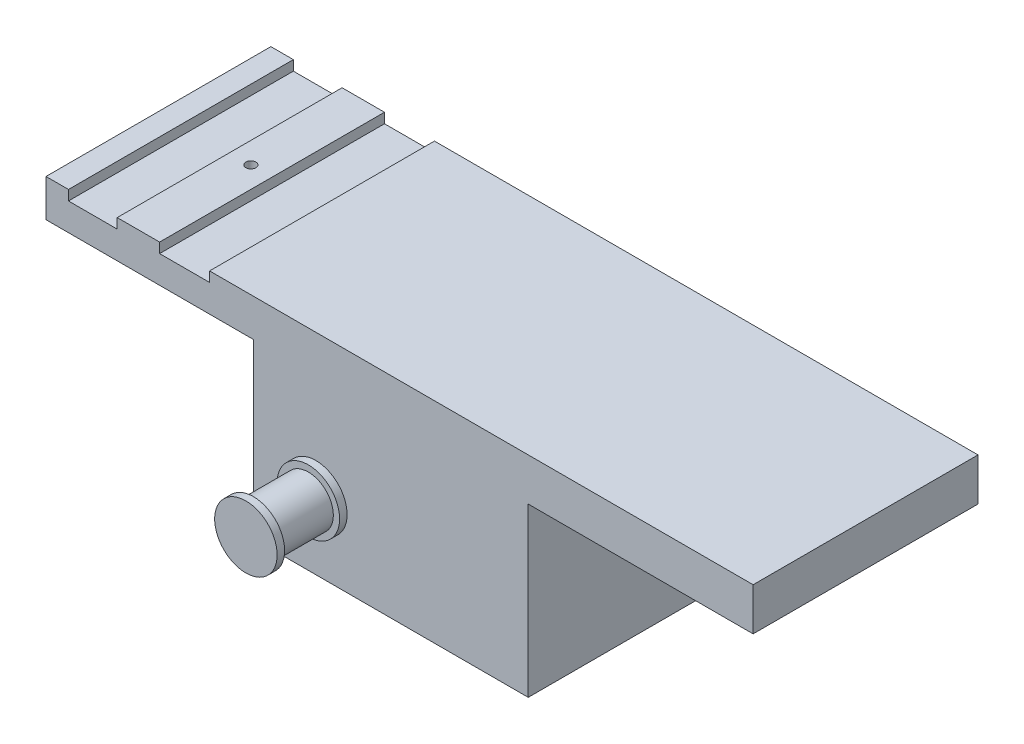
from build123d import *

# Parameters (mm, degrees)
BOSS_EXTRUDE1_DEPTH = 90
SKETCH2_R           = 2
CUT_EXTRUDE1_DEPTH  = 26
BOSS_EXTRUDE2_DEPTH = 90
SKETCH4_W           = 47.922407602
SKETCH4_H           = 26.699627092
BOSS_EXTRUDE3_DEPTH = 20
SKETCH7_R           = 2.5
CUT_EXTRUDE2_DEPTH  = 66.5
SKETCH9_W           = 15
SKETCH9_H           = 8
CUT_EXTRUDE3_DEPTH  = 91
CUT_EXTRUDE4_REACH  = 62.6
SKETCH8_R           = 2.5
CUT_EXTRUDE5_DEPTH  = 67
SKETCH12_W          = 63.84660413
SKETCH12_H          = 90
BOSS_EXTRUDE4_DEPTH = 67
BOSS_EXTRUDE5_START = -3
SKETCH13_R          = 10
BOSS_EXTRUDE5_DEPTH = 31
SKETCH15_R          = 12.5
BOSS_EXTRUDE6_DEPTH = 3
SKETCH16_R          = 12.5
BOSS_EXTRUDE7_DEPTH = 3
SKETCH17_W          = 34
SKETCH17_H          = 34
CUT_EXTRUDE6_DEPTH  = 2
SKETCH18_R          = 10
CUT_EXTRUDE7_DEPTH  = 5
SKETCH19_R          = 12.5
CUT_EXTRUDE8_DEPTH  = 3


with BuildPart() as part:
    # Sketch1 → Boss-Extrude1 (new body)
    with BuildSketch(Plane.XY):
        Polygon((-283, 0), (0, 0), (0, 15), (-217.53, 15), (-217.53, 11), (-237.53, 11), (-237.53, 15), (-254.5, 15), (-254.5, 11), (-274, 11), (-274, 15), (-283, 15), align=None)
    extrude(amount=BOSS_EXTRUDE1_DEPTH)

    # Sketch2 → Cut-Extrude1 (cut)
    with BuildSketch(Plane(origin=(0, 15, 0), x_dir=(1, 0, 0), z_dir=(0, 1, 0))):
        with Locations((-246.015, -45)):
            Circle(SKETCH2_R)
    extrude(amount=-CUT_EXTRUDE1_DEPTH, mode=Mode.SUBTRACT)

    # Sketch3 → Boss-Extrude2 (add)
    with BuildSketch(Plane(origin=(0, 0, 0), x_dir=(-1, 0, 0), z_dir=(0, 0, -1))):
        Polygon((0, 0), (0, -61.6), (0, -69.046795722), (8.076697935, -69.046795722), (16.610633667, -45.6), (63.389366333, -45.6), (71.923302065, -69.046795722), (128.076697935, -69.046795722), (136.610633667, -45.6), (183.389366333, -45.6), (191.923302065, -69.046795722), (200, -69.046795722), (200, -61.6), (200, 7.5), (0, 7.5), align=None)
    extrude(amount=-BOSS_EXTRUDE2_DEPTH)

    # Sketch4 → Boss-Extrude3 (add, symmetric)
    with BuildSketch(Plane(origin=(0, 0, 44.5), x_dir=(-1, 0, 0), z_dir=(0, 0, -1))):
        with Locations((40.197751444, -51.696982176)):
            Rectangle(SKETCH4_W, SKETCH4_H)
    extrude(amount=BOSS_EXTRUDE3_DEPTH, both=True)

    # Sketch7 → Cut-Extrude2 (cut, through all)
    with BuildSketch(Plane(origin=(0, 0, 24.5), x_dir=(-1, 0, 0), z_dir=(0, 0, -1))):
        with Locations((40, -61.6)):
            Circle(SKETCH7_R)
    extrude(amount=-CUT_EXTRUDE2_DEPTH, mode=Mode.SUBTRACT)

    # Sketch9 → Cut-Extrude3 (cut, through all)
    with BuildSketch(Plane(origin=(0, 0, 0), x_dir=(-1, 0, 0), z_dir=(0, 0, -1))):
        with Locations((160, -36.6)):
            Rectangle(SKETCH9_W, SKETCH9_H)
    extrude(amount=-CUT_EXTRUDE3_DEPTH, mode=Mode.SUBTRACT)

    # Sketch8 → Cut-Extrude4 (cut, up to next)
    with BuildSketch(Plane.XZ.offset(45.6), mode=Mode.PRIVATE) as cut_extrude4_sk1:
        with Locations((-160, 75)):
            Circle(SKETCH8_R)
    cut_extrude4_tool1 = extrude(cut_extrude4_sk1.sketch, amount=-CUT_EXTRUDE4_REACH, mode=Mode.PRIVATE) & part.part
    add(cut_extrude4_tool1.solids().sort_by_distance((-160, -45.6, 75))[0], mode=Mode.SUBTRACT)
    # Sketch8 → Cut-Extrude4 (cut, up to next)
    with BuildSketch(Plane.XZ.offset(45.6), mode=Mode.PRIVATE) as cut_extrude4_sk2:
        with Locations((-160, 15)):
            Circle(SKETCH8_R)
    cut_extrude4_tool2 = extrude(cut_extrude4_sk2.sketch, amount=-CUT_EXTRUDE4_REACH, mode=Mode.PRIVATE) & part.part
    add(cut_extrude4_tool2.solids().sort_by_distance((-160, -45.6, 15))[0], mode=Mode.SUBTRACT)

    # Sketch10 → Cut-Extrude5 (cut)
    with BuildSketch(Plane.XZ.offset(69.046795722)):
        Polygon((-8.076697935, 90), (-90, 90), (-90, 0), (-8.076697935, 0), (0, 0), (0, 90), align=None)
    extrude(amount=-CUT_EXTRUDE5_DEPTH, mode=Mode.SUBTRACT)

    # Sketch12 → Boss-Extrude4 (add)
    with BuildSketch(Plane.XZ.offset(69.046795722)):
        with Locations((-160, 45)):
            Rectangle(SKETCH12_W, SKETCH12_H)
    extrude(amount=-BOSS_EXTRUDE4_DEPTH)

    # Sketch13 → Boss-Extrude5 (add)
    with BuildSketch(Plane.XY.offset(90).offset(BOSS_EXTRUDE5_START)):
        with Locations((-175, -41.946795722)):
            Circle(SKETCH13_R)
    boss_extrude5 = extrude(amount=BOSS_EXTRUDE5_DEPTH)

    # Sketch15 → Boss-Extrude6 (add)
    with BuildSketch(Plane.XY.offset(118)):
        with Locations((-175, -41.946795722)):
            Circle(SKETCH15_R)
    boss_extrude6 = extrude(amount=-BOSS_EXTRUDE6_DEPTH)

    # Mirror1: Boss-Extrude5, Boss-Extrude6 across plane
    add(boss_extrude5.mirror(Plane(origin=(0, 0, 44.5), x_dir=(1, 0, 0), z_dir=(0, 0, -1))))
    add(boss_extrude6.mirror(Plane(origin=(0, 0, 44.5), x_dir=(1, 0, 0), z_dir=(0, 0, -1))))

    # Sketch16 → Boss-Extrude7 (add)
    with BuildSketch(Plane.XY.offset(90)):
        with Locations((-175, -41.946795722)):
            Circle(SKETCH16_R)
    boss_extrude7 = extrude(amount=BOSS_EXTRUDE7_DEPTH)

    # Mirror2: Boss-Extrude7 across plane
    add(boss_extrude7.mirror(Plane(origin=(0, 0, 44.5), x_dir=(1, 0, 0), z_dir=(0, 0, -1))))

    # Sketch17 → Cut-Extrude6 (cut)
    with BuildSketch(Plane(origin=(0, -2.046795722, 0), x_dir=(-1, 0, 0), z_dir=(0, -1, 0))):
        with Locations((37, -45)):
            Rectangle(SKETCH17_W, SKETCH17_H)
    extrude(amount=-CUT_EXTRUDE6_DEPTH, mode=Mode.SUBTRACT)

    # Sketch18 → Cut-Extrude7 (cut)
    with BuildSketch(Plane.XZ.offset(0.046795722)):
        with Locations((-37, 45)):
            Circle(SKETCH18_R)
    extrude(amount=-CUT_EXTRUDE7_DEPTH, mode=Mode.SUBTRACT)

    # Sketch19 → Cut-Extrude8 (cut)
    with BuildSketch(Plane.XZ.offset(-4.953204278)):
        with Locations((-37, 45)):
            Circle(SKETCH19_R)
    extrude(amount=-CUT_EXTRUDE8_DEPTH, mode=Mode.SUBTRACT)


solid = part.part
